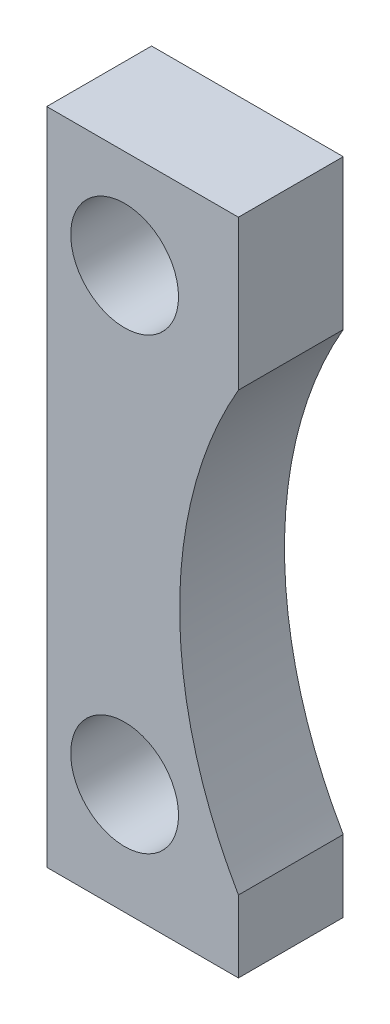
from build123d import *

# Parameters (mm, degrees)
Y_KSEKLIK_EKSTR_ZYON1_DEPTH = 8.75
IZIM2_R                     = 9
KES_EKSTR_ZYON1_DEPTH       = 18.5


with BuildPart() as part:
    # Çizim1 → Yükseklik-Ekstrüzyon1 (new body, symmetric)
    with BuildSketch(Plane.XY):
        with BuildLine():
            Line((0, 0), (0, 110))
            Line((0, 110), (32, 110))
            Line((32, 110), (32, 85))
            ThreePointArc((32, 85), (22.190316578, 48.5), (32, 12))
            Line((32, 12), (32, 0))
            Line((32, 0), (0, 0))
        make_face()
    extrude(amount=Y_KSEKLIK_EKSTR_ZYON1_DEPTH, both=True)

    # Çizim2 → Kes-Ekstrüzyon1 (cut, through all)
    with BuildSketch(Plane.XY.offset(8.75)):
        with Locations((13, 93.5)):
            Circle(IZIM2_R)
        with Locations((13, 18.5)):
            Circle(IZIM2_R)
    extrude(amount=-KES_EKSTR_ZYON1_DEPTH, mode=Mode.SUBTRACT)


solid = part.part
